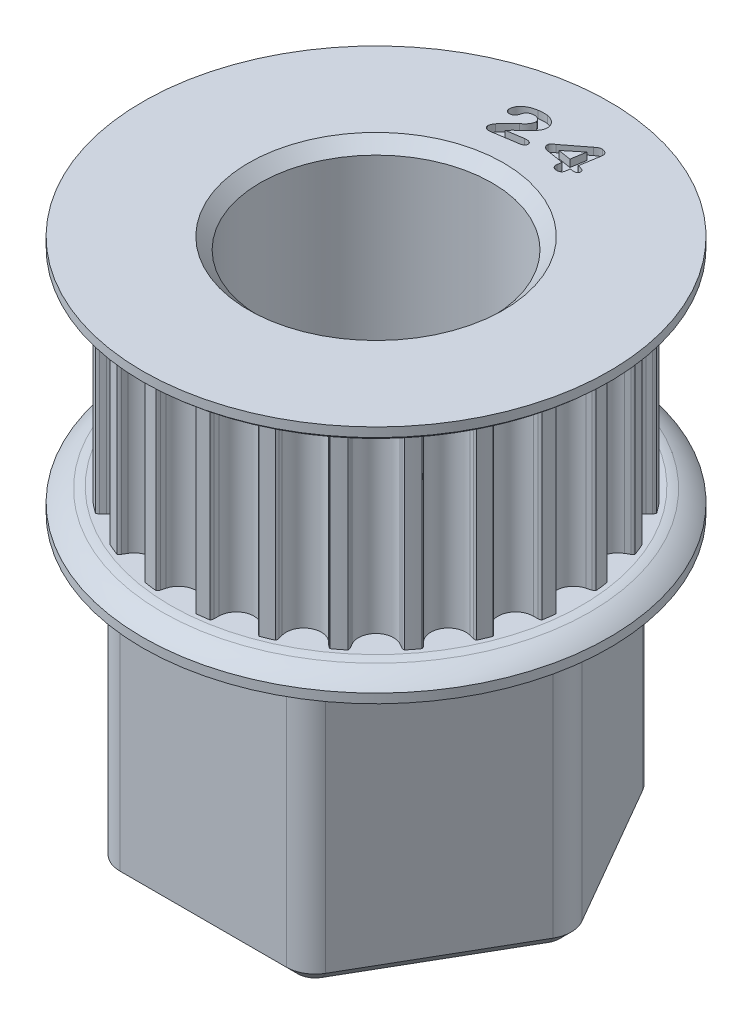
from build123d import *

# Parameters (mm, degrees)
SKETCH1_R                    = 11.078156269
TOOTHOD_DEPTH                = 5.334
TOOTHPROFILE_DEPTH           = 6.334
TOOTHPATTERN_COUNT           = 24
SKETCH7_R                    = 6.3881
BORE_DEPTH                   = 7.604
BORE_DEPTH_BACK              = 7.604
SMALL_TOOTH_COUNT_DEPTH      = 1
SMALL_TOOTH_COUNT_DEPTH_BACK = 0.4
SKETCH12_R                   = 6.3881
BOSS_EXTRUDE1_DEPTH          = 15.24
FILLET1_R                    = 1.5875
CUT_SWEEP1_PROFILE_R         = 0.3175
FILLET2_R                    = 1.27
CHAMFER1_SIZE                = 0.635
CHAMFER2_SIZE                = 0.635


with BuildPart() as part:
    # Sketch1 → ToothOD (new body, symmetric)
    with BuildSketch(Plane(origin=(0, 0, 0), x_dir=(1, 0, 0), z_dir=(0, 1, 0))):
        Circle(SKETCH1_R)
    extrude(amount=TOOTHOD_DEPTH, both=True)

    # Sketch2 → ToothProfile (cut, symmetric)
    with BuildSketch(Plane(origin=(0, 0, 0), x_dir=(1, 0, 0), z_dir=(0, 1, 0))):
        with BuildLine():
            ThreePointArc((-0.937033068, 10.628218265), (-0.590385173, 10.110043655), (0, 9.909756269))
            ThreePointArc((0, 9.909756269), (0.590385173, 10.110043655), (0.937033068, 10.628218265))
            ThreePointArc((0.937033068, 10.628218265), (0.971699064, 10.754329727), (1.007805813, 10.880036269))
            ThreePointArc((1.007805813, 10.880036269), (1.043742495, 10.958436311), (1.100516181, 11.023357495))
            ThreePointArc((1.100516181, 11.023357495), (0, 11.078156269), (-1.100516181, 11.023357495))
            ThreePointArc((-1.100516181, 11.023357495), (-1.043742495, 10.958436311), (-1.007805813, 10.880036269))
            ThreePointArc((-1.007805813, 10.880036269), (-0.971699064, 10.754329727), (-0.937033068, 10.628218265))
        make_face()
    toothprofile = extrude(amount=TOOTHPROFILE_DEPTH, both=True, mode=Mode.SUBTRACT)

    # ToothPattern: ToothProfile ×24 about axis
    toothpattern_axis = Axis((0, 0, 0), (0, 1, 0))
    for i in range(1, TOOTHPATTERN_COUNT):
        add(toothprofile.rotate(toothpattern_axis, i * 360 / TOOTHPATTERN_COUNT), mode=Mode.SUBTRACT)

    # Sketch4 → Flange (revolve)
    with BuildSketch(Plane.XY):
        with BuildLine():
            Line((0, -5.334), (11.332156269, -5.334))
            ThreePointArc((11.332156269, -5.334), (11.56180289, -5.369951298), (11.787228598, -5.426637424))
            ThreePointArc((11.787228598, -5.426637424), (12.354957174, -5.708197125), (12.856156269, -6.096))
            Line((12.856156269, -6.096), (12.856156269, -6.604))
            Line((12.856156269, -6.604), (0, -6.604))
            Line((0, -6.604), (0, -5.334))
        make_face()
        with BuildLine():
            Line((12.856156269, 6.604), (12.856156269, 6.096))
            ThreePointArc((12.856156269, 6.096), (12.354957174, 5.708197125), (11.787228598, 5.426637424))
            ThreePointArc((11.787228598, 5.426637424), (11.56180289, 5.369951298), (11.332156269, 5.334))
            Line((11.332156269, 5.334), (0, 5.334))
            Line((0, 5.334), (0, 6.604))
            Line((0, 6.604), (12.856156269, 6.604))
        make_face()
    revolve(axis=Axis((0, 8.73125, 0), (0, -1, 0)))

    # Sketch7 → Bore (cut, two sides)
    with BuildSketch(Plane.XZ) as bore_sk:
        Circle(SKETCH7_R)
    extrude(amount=BORE_DEPTH, mode=Mode.SUBTRACT)
    extrude(bore_sk.sketch, amount=-BORE_DEPTH_BACK, mode=Mode.SUBTRACT)

    # Sketch11 → Small Tooth Count (cut, two sides)
    with BuildSketch(Plane(origin=(0, 6.604, 0), x_dir=(1, 0, 0), z_dir=(0, 1, 0))) as small_tooth_count_sk:
        with BuildLine():
            Line((-1.506669992, 8.621605484), (-0.594948898, 8.761801578))
            add(Edge.make_bspline(
                [(-0.594948898, 8.761801578), (-0.568508634, 8.765198423), (-0.51843609, 8.771631365), (-0.44654772, 8.772071074), (-0.382615431, 8.763265759), (-0.327096583, 8.746782768), (-0.28073736, 8.722976742), (-0.245229797, 8.692438756), (-0.219549143, 8.656177692), (-0.213233627, 8.628356784), (-0.210079367, 8.614461734)],
                knots=[0, 0, 0, 0, 7.9926e-05, 0.000151363, 0.000214948, 0.000272853, 0.000324383, 0.000369955, 0.00041243, 0.00045481, 0.00045481, 0.00045481, 0.00045481], degree=3))
            add(Edge.make_bspline(
                [(-0.210079367, 8.614461734), (-0.208889964, 8.601771408), (-0.206493047, 8.576197502), (-0.216741472, 8.537560395), (-0.235628299, 8.499855984), (-0.26391302, 8.463095811), (-0.302942444, 8.429662764), (-0.353193783, 8.402600281), (-0.413829448, 8.381641212), (-0.458320193, 8.373612775), (-0.481988351, 8.369341812)],
                knots=[0, 0, 0, 0, 3.7975e-05, 7.6528e-05, 0.000117861, 0.00016403, 0.000214686, 0.000270846, 0.000334248, 0.000406315, 0.000406315, 0.000406315, 0.000406315], degree=3))
            Line((-0.481988351, 8.369341812), (-1.850909445, 8.159494156))
            add(Edge.make_bspline(
                [(-1.850909445, 8.159494156), (-1.874677499, 8.156558384), (-1.920064022, 8.15095235), (-1.985993536, 8.153953423), (-2.045566646, 8.166819623), (-2.097937256, 8.188882133), (-2.141644576, 8.218958806), (-2.176056266, 8.25450227), (-2.200261447, 8.296079566), (-2.206948594, 8.326650658), (-2.210329367, 8.342106266)],
                knots=[0, 0, 0, 0, 7.1751e-05, 0.000137012, 0.000196918, 0.000253727, 0.000306363, 0.000354999, 0.000401186, 0.000448412, 0.000448412, 0.000448412, 0.000448412], degree=3))
            add(Edge.make_bspline(
                [(-2.210329367, 8.342106266), (-2.211321429, 8.35297506), (-2.213474856, 8.376567494), (-2.207871102, 8.414736071), (-2.197602748, 8.457816322), (-2.181066772, 8.504044131), (-2.161523691, 8.550563815), (-2.139011673, 8.59387946), (-2.114771053, 8.632517333), (-2.096113828, 8.655263986), (-2.087099679, 8.666253922)],
                knots=[0, 0, 0, 0, 3.2642e-05, 7.0855e-05, 0.000114931, 0.00016548, 0.000217892, 0.00026622, 0.000311798, 0.000354404, 0.000354404, 0.000354404, 0.000354404], degree=3))
            add(Edge.make_bspline(
                [(-2.087099679, 8.666253922), (-2.051926797, 8.70563464), (-1.983635312, 8.782096037), (-1.882781696, 8.891706347), (-1.787421488, 8.993402689), (-1.71040015, 9.071642309), (-1.653062288, 9.130098592), (-1.613191617, 9.168811361), (-1.576609875, 9.204115545), (-1.543103636, 9.235957396), (-1.512499045, 9.26401221), (-1.484693768, 9.288140763), (-1.460222689, 9.308797929), (-1.444641349, 9.320989249), (-1.437464914, 9.326604312)],
                knots=[0, 0, 0, 0, 0.000158401, 0.000307551, 0.000446841, 0.000576608, 0.00063691, 0.000692479, 0.000743317, 0.000789428, 0.000831146, 0.000867855, 0.000899868, 0.000927203, 0.000927203, 0.000927203, 0.000927203], degree=3))
            add(Edge.make_bspline(
                [(-1.437464914, 9.326604312), (-1.415699138, 9.344096052), (-1.373639167, 9.377896918), (-1.31556485, 9.430556423), (-1.263091792, 9.481497265), (-1.217417118, 9.532268382), (-1.177355276, 9.581870506), (-1.143339078, 9.630659742), (-1.115770383, 9.678955907), (-1.094008941, 9.726222335), (-1.079010073, 9.772608594), (-1.068990971, 9.817254636), (-1.066125276, 9.860516575), (-1.069031756, 9.888447706), (-1.070454757, 9.902122672)],
                knots=[0, 0, 0, 0, 8.3751e-05, 0.00016184, 0.000235088, 0.000303055, 0.000366578, 0.000426274, 0.000481266, 0.000533219, 0.000582072, 0.000627257, 0.000670204, 0.000711399, 0.000711399, 0.000711399, 0.000711399], degree=3))
            add(Edge.make_bspline(
                [(-1.070454757, 9.902122672), (-1.073101852, 9.915947961), (-1.078327528, 9.943240708), (-1.094494112, 9.981703166), (-1.116615509, 10.017043528), (-1.145060228, 10.04859137), (-1.178300901, 10.076950508), (-1.216302468, 10.101048218), (-1.258889714, 10.120303405), (-1.305215474, 10.134908931), (-1.354364351, 10.144457895), (-1.405333989, 10.149506523), (-1.457750016, 10.149178642), (-1.492860178, 10.144637273), (-1.510688351, 10.142331266)],
                knots=[0, 0, 0, 0, 4.2133e-05, 8.3176e-05, 0.000124303, 0.000166684, 0.000210076, 0.000255038, 0.00030119, 0.000349906, 0.00040043, 0.000451121, 0.000503362, 0.000557253, 0.000557253, 0.000557253, 0.000557253], degree=3))
            add(Edge.make_bspline(
                [(-1.510688351, 10.142331266), (-1.527596498, 10.139296406), (-1.560826651, 10.133331894), (-1.608260799, 10.117909964), (-1.652483903, 10.098012849), (-1.693864274, 10.074084955), (-1.731680005, 10.044484021), (-1.76651825, 10.010598615), (-1.798089169, 9.971893058), (-1.815934823, 9.943404547), (-1.825013351, 9.928911734)],
                knots=[0, 0, 0, 0, 5.1487e-05, 0.00010119, 0.000149153, 0.000196783, 0.000244205, 0.000292828, 0.000342338, 0.000393606, 0.000393606, 0.000393606, 0.000393606], degree=3))
            add(Edge.make_bspline(
                [(-1.825013351, 9.928911734), (-1.826559277, 9.925360904), (-1.831340104, 9.91437984), (-1.837656207, 9.890979564), (-1.847717966, 9.855611617), (-1.859566069, 9.81054411), (-1.873864818, 9.760908096), (-1.893574508, 9.713288417), (-1.916666393, 9.669565796), (-1.942422798, 9.628901741), (-1.976575179, 9.593383256), (-2.021136356, 9.565627073), (-2.075687033, 9.545210856), (-2.115811032, 9.537738725), (-2.137105929, 9.533773062)],
                knots=[0, 0, 0, 0, 1.1609e-05, 3.59e-05, 7.2514e-05, 0.000122012, 0.000175683, 0.000227338, 0.000276269, 0.000323944, 0.000371305, 0.000422705, 0.000480085, 0.000544979, 0.000544979, 0.000544979, 0.000544979], degree=3))
            add(Edge.make_bspline(
                [(-2.137105929, 9.533773062), (-2.153754851, 9.531867902), (-2.186007077, 9.528177233), (-2.23368108, 9.532108784), (-2.278463536, 9.542658983), (-2.31955032, 9.560810626), (-2.355603746, 9.586270992), (-2.383667544, 9.619490715), (-2.403753934, 9.659477168), (-2.40984827, 9.688934956), (-2.413033273, 9.704330094)],
                knots=[0, 0, 0, 0, 5.0167e-05, 9.7184e-05, 0.000142666, 0.000187637, 0.000231132, 0.000273895, 0.000316825, 0.000363822, 0.000363822, 0.000363822, 0.000363822], degree=3))
            add(Edge.make_bspline(
                [(-2.413033273, 9.704330094), (-2.415009696, 9.722614032), (-2.419038371, 9.759883408), (-2.41588734, 9.817423499), (-2.405366179, 9.876857396), (-2.387446287, 9.937809803), (-2.362210558, 9.998975276), (-2.32919863, 10.0590732), (-2.288238244, 10.117088054), (-2.239926945, 10.173568432), (-2.18329972, 10.227352379), (-2.118289715, 10.277709516), (-2.044964572, 10.324806196), (-1.963139928, 10.367987482), (-1.872740102, 10.406840276), (-1.773817701, 10.440289158), (-1.666292684, 10.467537519), (-1.591307924, 10.480391675), (-1.552657882, 10.487017203)],
                knots=[0, 0, 0, 0, 5.5099e-05, 0.000112312, 0.000172135, 0.000235858, 0.000302522, 0.000370261, 0.000441111, 0.000515206, 0.000592894, 0.000674972, 0.000761542, 0.000854017, 0.000952216, 0.001056416, 0.00116698, 0.001284588, 0.001284588, 0.001284588, 0.001284588], degree=3))
            add(Edge.make_bspline(
                [(-1.552657882, 10.487017203), (-1.52841577, 10.490420955), (-1.480751914, 10.497113273), (-1.410338577, 10.504749177), (-1.342432419, 10.509701208), (-1.277046262, 10.51204123), (-1.214045238, 10.511479586), (-1.153411338, 10.508973664), (-1.095114995, 10.503782012), (-1.05733219, 10.497930911), (-1.038754367, 10.495053922)],
                knots=[0, 0, 0, 0, 7.3437e-05, 0.000144389, 0.000212432, 0.000277657, 0.000340612, 0.000401393, 0.000459683, 0.000516069, 0.000516069, 0.000516069, 0.000516069], degree=3))
            add(Edge.make_bspline(
                [(-1.038754367, 10.495053922), (-1.012752892, 10.489369266), (-0.96200432, 10.478274198), (-0.888985545, 10.45489373), (-0.821106831, 10.425791147), (-0.75796727, 10.391965838), (-0.700394534, 10.353338936), (-0.647860502, 10.311763872), (-0.60189878, 10.265513926), (-0.561703519, 10.21630272), (-0.52825955, 10.16388857), (-0.500935533, 10.109658948), (-0.481526714, 10.052937679), (-0.474093975, 10.014001671), (-0.470379757, 9.994544937)],
                knots=[0, 0, 0, 0, 7.9816e-05, 0.000155781, 0.000229592, 0.000301109, 0.000370331, 0.000437341, 0.000501746, 0.00056555, 0.0006276, 0.000687902, 0.000747344, 0.000806719, 0.000806719, 0.000806719, 0.000806719], degree=3))
            add(Edge.make_bspline(
                [(-0.470379757, 9.994544937), (-0.468313859, 9.979241775), (-0.464214985, 9.948879331), (-0.463028656, 9.902976173), (-0.465763305, 9.85759698), (-0.472017419, 9.812321869), (-0.482311465, 9.767549639), (-0.496288954, 9.722898988), (-0.514091815, 9.678640488), (-0.543276505, 9.621627388), (-0.5821308, 9.554514276), (-0.631232404, 9.480877647), (-0.681592679, 9.416301746), (-0.726197052, 9.368271741), (-0.764793863, 9.33139352), (-0.797639899, 9.300077015), (-0.835761225, 9.26560612), (-0.877842806, 9.226250562), (-0.924928843, 9.183462306), (-0.976268817, 9.136246595), (-1.032855305, 9.085860231), (-1.092257956, 9.032453687), (-1.15175781, 8.978868961), (-1.207750431, 8.927106786), (-1.258421687, 8.87803841), (-1.304564576, 8.832351062), (-1.346165344, 8.790274212), (-1.382469769, 8.750659594), (-1.414153642, 8.714540455), (-1.432796387, 8.690739083), (-1.441483273, 8.679648453)],
                knots=[0, 0, 0, 0, 4.6299e-05, 9.186e-05, 0.00013748, 0.000182564, 0.000228813, 0.000275132, 0.000322805, 0.000371725, 0.000467146, 0.000555315, 0.000637041, 0.00071255, 0.000751703, 0.000797183, 0.000848692, 0.000905878, 0.000970031, 0.001039559, 0.001115126, 0.00119733, 0.001279202, 0.001355342, 0.001426073, 0.001490795, 0.001550152, 0.001603553, 0.001651982, 0.001694237, 0.001694237, 0.001694237, 0.001694237], degree=3))
            add(Edge.make_bspline(
                [(-1.441483273, 8.679648453), (-1.451024119, 8.669362064), (-1.470895109, 8.64793831), (-1.494433375, 8.630612493), (-1.506669992, 8.621605484)],
                knots=[0, 0, 0, 0, 4.1991e-05, 8.7456e-05, 8.7456e-05, 8.7456e-05, 8.7456e-05], degree=3))
        make_face()
        with BuildLine():
            Line((1.55101935, 8.418337433), (1.58986349, 8.657206573))
            Line((1.58986349, 8.657206573), (0.687072084, 8.804099933))
            add(Edge.make_bspline(
                [(0.687072084, 8.804099933), (0.672000892, 8.806741232), (0.642738196, 8.811869661), (0.600810489, 8.822399788), (0.561659252, 8.833606125), (0.526052232, 8.847723884), (0.49325817, 8.862566946), (0.463946389, 8.879844481), (0.437487068, 8.898471155), (0.414229874, 8.918944931), (0.394394887, 8.941043653), (0.3777235, 8.964388587), (0.364276625, 8.988924673), (0.354172911, 9.014710713), (0.348258344, 9.041703291), (0.344382255, 9.06962205), (0.344406118, 9.09891493), (0.347202432, 9.118597173), (0.348636928, 9.128694073)],
                knots=[0, 0, 0, 0, 4.5886e-05, 8.9094e-05, 0.000129635, 0.000167942, 0.000203897, 0.000237514, 0.00026985, 0.000300847, 0.000330251, 0.000358746, 0.000386718, 0.000413997, 0.000441506, 0.000469417, 0.000498439, 0.000529009, 0.000529009, 0.000529009, 0.000529009], degree=3))
            add(Edge.make_bspline(
                [(0.348636928, 9.128694073), (0.351090473, 9.140034839), (0.356004071, 9.162746447), (0.37336919, 9.194608637), (0.397597542, 9.224376541), (0.427253538, 9.253217688), (0.460197633, 9.280208705), (0.493160259, 9.30650456), (0.526830527, 9.330042268), (0.551301349, 9.341407655), (0.563395912, 9.347024933)],
                knots=[0, 0, 0, 0, 3.4657e-05, 6.9405e-05, 0.000107547, 0.000149538, 0.000193271, 0.00023525, 0.000276115, 0.00031605, 0.00031605, 0.00031605, 0.00031605], degree=3))
            Line((0.563395912, 9.347024933), (1.726934193, 10.244012042))
            add(Edge.make_bspline(
                [(1.726934193, 10.244012042), (1.745455489, 10.257963538), (1.780367267, 10.284261458), (1.830792076, 10.319655435), (1.875735016, 10.348586491), (1.915975089, 10.372543351), (1.955715965, 10.388864789), (1.997117102, 10.398536139), (2.041252917, 10.400673528), (2.071056423, 10.396874001), (2.086354115, 10.394923761)],
                knots=[0, 0, 0, 0, 6.9563e-05, 0.000131123, 0.000184749, 0.000229939, 0.000271395, 0.000313093, 0.000356905, 0.000403109, 0.000403109, 0.000403109, 0.000403109], degree=3))
            add(Edge.make_bspline(
                [(2.086354115, 10.394923761), (2.099950722, 10.392636805), (2.126158697, 10.388228611), (2.163530831, 10.37784315), (2.198177308, 10.367161507), (2.229931127, 10.354127612), (2.258285181, 10.338868891), (2.284274792, 10.322533926), (2.306434796, 10.303430926), (2.326623159, 10.283439947), (2.343027156, 10.260768158), (2.357095196, 10.236647038), (2.36772325, 10.210618693), (2.375523933, 10.182922916), (2.379710956, 10.153359512), (2.3815777, 10.121992701), (2.380223715, 10.088784623), (2.376927183, 10.066288119), (2.375229506, 10.054702667)],
                knots=[0, 0, 0, 0, 4.1333e-05, 7.9671e-05, 0.000116242, 0.000150072, 0.000182429, 0.00021277, 0.000241925, 0.000270025, 0.000297797, 0.000325598, 0.000353623, 0.000381897, 0.000411701, 0.000443006, 0.000476073, 0.000511184, 0.000511184, 0.000511184, 0.000511184], degree=3))
            Line((2.375229506, 10.054702667), (2.193510365, 8.940277667))
            Line((2.193510365, 8.940277667), (2.216281068, 8.936705792))
            add(Edge.make_bspline(
                [(2.216281068, 8.936705792), (2.241193074, 8.932091848), (2.288965188, 8.923243991), (2.357158875, 8.905696845), (2.418091811, 8.882988992), (2.464944242, 8.862355753), (2.49722756, 8.842401913), (2.517904876, 8.826459131), (2.53406144, 8.807761472), (2.546929047, 8.787559106), (2.555370678, 8.765194718), (2.560413445, 8.74125672), (2.561168806, 8.715455659), (2.558976977, 8.697966373), (2.557841615, 8.688906964)],
                knots=[0, 0, 0, 0, 7.6005e-05, 0.000145749, 0.000210864, 0.000270987, 0.000298863, 0.000324593, 0.000348954, 0.000372618, 0.000396083, 0.00042025, 0.000445716, 0.000473083, 0.000473083, 0.000473083, 0.000473083], degree=3))
            add(Edge.make_bspline(
                [(2.557841615, 8.688906964), (2.554520452, 8.67473757), (2.548041087, 8.647094043), (2.523852738, 8.611284281), (2.489399567, 8.583576013), (2.445267354, 8.563875927), (2.392370456, 8.551964631), (2.331419439, 8.546892728), (2.262560581, 8.549495369), (2.21444511, 8.556287496), (2.189045521, 8.559872979)],
                knots=[0, 0, 0, 0, 4.3364e-05, 8.4601e-05, 0.00012679, 0.000174533, 0.000228247, 0.00028876, 0.000357555, 0.000434477, 0.000434477, 0.000434477, 0.000434477], degree=3))
            Line((2.189045521, 8.559872979), (2.13278849, 8.568802667))
            Line((2.13278849, 8.568802667), (2.09394435, 8.329933526))
            add(Edge.make_bspline(
                [(2.09394435, 8.329933526), (2.090019799, 8.31187243), (2.082483489, 8.277189727), (2.06035015, 8.229811046), (2.028427267, 8.190889739), (1.988767083, 8.159652081), (1.941441543, 8.137876464), (1.88844883, 8.124793342), (1.829599126, 8.12203693), (1.789250213, 8.126901407), (1.768010756, 8.129462042)],
                knots=[0, 0, 0, 0, 5.5337e-05, 0.000106264, 0.000155145, 0.000205074, 0.000256404, 0.000310223, 0.000367904, 0.000432015, 0.000432015, 0.000432015, 0.000432015], degree=3))
            add(Edge.make_bspline(
                [(1.768010756, 8.129462042), (1.74999432, 8.133208829), (1.715228917, 8.140438813), (1.667113738, 8.160244967), (1.625751617, 8.187418032), (1.591227716, 8.221249557), (1.564518328, 8.261748455), (1.549514744, 8.309505798), (1.544018398, 8.362576467), (1.548612232, 8.399165297), (1.55101935, 8.418337433)],
                knots=[0, 0, 0, 0, 5.512e-05, 0.000106363, 0.00015503, 0.000202704, 0.000250509, 0.000298937, 0.00035145, 0.000409256, 0.000409256, 0.000409256, 0.000409256], degree=3))
        make_face()
        Polygon((0.938442787, 9.144321026), (1.650585365, 9.028681573), (1.780958803, 9.828781573), align=None, mode=Mode.SUBTRACT)
    extrude(amount=SMALL_TOOTH_COUNT_DEPTH, mode=Mode.SUBTRACT)
    extrude(small_tooth_count_sk.sketch, amount=-SMALL_TOOTH_COUNT_DEPTH_BACK, mode=Mode.SUBTRACT)

    # Sketch12 → Boss-Extrude1 (add)
    with BuildSketch(Plane.XZ.offset(6.604)):
        Polygon((5.499261314, -9.525), (10.998522628, 0), (5.499261314, 9.525), (-5.499261314, 9.525), (-10.998522628, 0), (-5.499261314, -9.525), align=None)
        Circle(SKETCH12_R, mode=Mode.SUBTRACT)
    extrude(amount=BOSS_EXTRUDE1_DEPTH)

    # Fillet1
    fillet1_edges = [part.edges().sort_by_distance(p)[0] for p in [
        (-5.499261314, -14.224, -9.525),
        (5.499261314, -14.224, -9.525),
        (10.998522628, -14.224, 0),
        (5.499261314, -14.224, 9.525),
        (-5.499261314, -14.224, 9.525),
        (-10.998522628, -14.224, 0),
    ]]
    fillet(fillet1_edges, radius=FILLET1_R)

    # Cut-Sweep1: sweep along a path in Sketch25
    with BuildLine(Plane.XZ.offset(6.604)) as cut_sweep1_path:
        Line((-4.582717762, -9.525), (4.582717762, -9.525))
        ThreePointArc((4.582717762, -9.525), (5.376467762, -9.312315329), (5.95753309, -8.73125))
        Line((5.95753309, -8.73125), (10.540250852, -0.79375))
        ThreePointArc((10.540250852, -0.79375), (10.752935523, 0), (10.540250852, 0.79375))
        Line((10.540250852, 0.79375), (5.95753309, 8.73125))
        ThreePointArc((5.95753309, 8.73125), (5.376467762, 9.312315329), (4.582717762, 9.525))
        Line((4.582717762, 9.525), (-4.582717762, 9.525))
        ThreePointArc((-4.582717762, 9.525), (-5.376467762, 9.312315329), (-5.95753309, 8.73125))
        Line((-5.95753309, 8.73125), (-10.540250852, 0.79375))
        ThreePointArc((-10.540250852, 0.79375), (-10.752935523, 0), (-10.540250852, -0.79375))
        Line((-10.540250852, -0.79375), (-5.95753309, -8.73125))
        ThreePointArc((-5.95753309, -8.73125), (-5.376467762, -9.312315329), (-4.582717762, -9.525))
    # Cut-Sweep1 profile (on start of the path) → Cut-Sweep1 (sweep, cut)
    with BuildSketch(Plane(origin=(-4.582717762, -6.604, -9.525), x_dir=(0, 0, 1), z_dir=(1, 0, 0))):
        Circle(CUT_SWEEP1_PROFILE_R)
    sweep(path=cut_sweep1_path.line, mode=Mode.SUBTRACT)

    # Fillet2
    fillet2_edges = [part.edges().sort_by_distance(p)[0] for p in [
        (-5.376467762, -6.9215, -9.312315329),
        (-10.752935523, -6.9215, 0),
        (5.376467762, -6.9215, -9.312315329),
        (10.752935523, -6.9215, 0),
        (5.376467762, -6.9215, 9.312315329),
        (-5.376467762, -6.9215, 9.312315329),
        (-8.248891971, -6.9215, -4.7625),
        (-8.248891971, -6.9215, 4.7625),
        (0, -6.9215, 9.525),
        (8.248891971, -6.9215, 4.7625),
        (8.248891971, -6.9215, -4.7625),
        (0, -6.9215, -9.525),
        (-5.535217762, -6.604, -9.587278394),
        (-8.523855037, -6.604, -4.92125),
        (-11.070435523, -6.604, 0),
        (-8.523855037, -6.604, 4.92125),
        (-5.535217762, -6.604, 9.587278394),
        (0, -6.604, 9.8425),
        (5.535217762, -6.604, 9.587278394),
        (8.523855037, -6.604, 4.92125),
        (11.070435523, -6.604, 0),
        (8.523855037, -6.604, -4.92125),
        (5.535217762, -6.604, -9.587278394),
        (0, -6.604, -9.8425),
    ]]
    fillet(fillet2_edges, radius=FILLET2_R)

    # Chamfer1
    chamfer1_edges = [part.edges().sort_by_distance(p)[0] for p in [
        (-6.3881, 6.604, 0),
        (-6.3881, -21.844, 0),
    ]]
    chamfer(chamfer1_edges, length=CHAMFER1_SIZE)

    # Chamfer2
    chamfer2_edges = [part.edges().sort_by_distance(p)[0] for p in [
        (-8.248891971, -21.844, 4.7625),
        (0, -21.844, 9.525),
        (0, -21.844, -9.525),
        (8.248891971, -21.844, -4.7625),
        (8.248891971, -21.844, 4.7625),
        (-8.248891971, -21.844, -4.7625),
        (-5.376467762, -21.844, -9.312315329),
        (-10.752935523, -21.844, 0),
        (5.376467762, -21.844, -9.312315329),
        (10.752935523, -21.844, 0),
        (5.376467762, -21.844, 9.312315329),
        (-5.376467762, -21.844, 9.312315329),
    ]]
    chamfer(chamfer2_edges, length=CHAMFER2_SIZE)


solid = part.part
